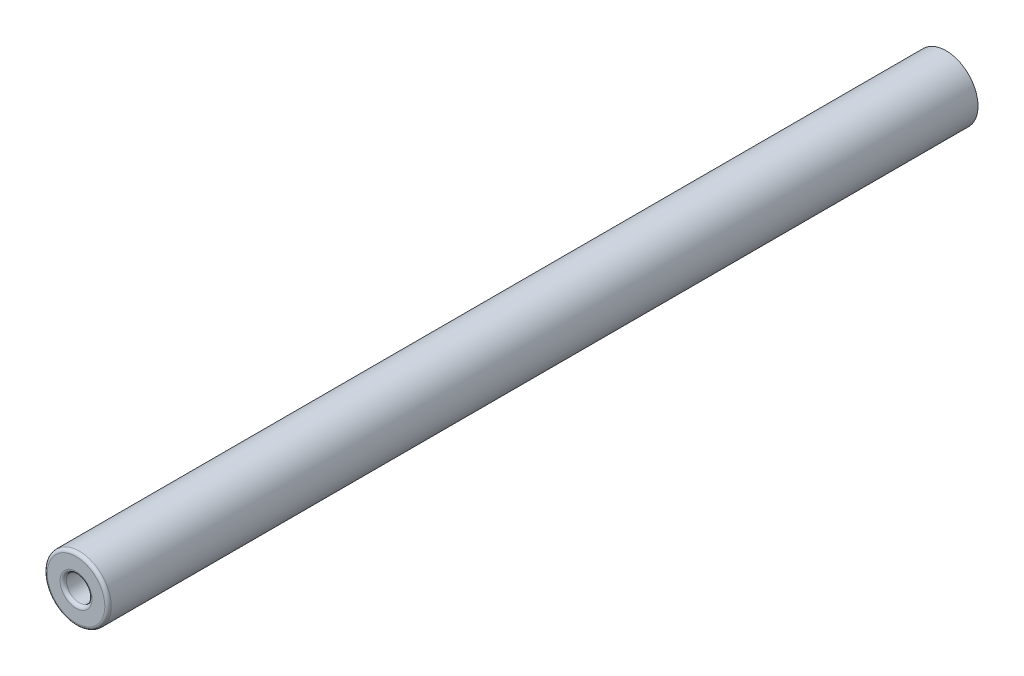
from build123d import *

# Parameters (mm, degrees)
SKETCH1_R           = 5
BOSS_EXTRUDE1_DEPTH = 136
SKETCH2_R           = 2
CUT_EXTRUDE1_DEPTH  = 20
FILLET1_R           = 0.5
FILLET2_R           = 0.5


with BuildPart() as part:
    # Sketch1 → Boss-Extrude1 (new body)
    with BuildSketch(Plane.XY):
        Circle(SKETCH1_R)
    extrude(amount=BOSS_EXTRUDE1_DEPTH)

    # Sketch2 → Cut-Extrude1 (cut)
    with BuildSketch(Plane.XY.offset(136)):
        Circle(SKETCH2_R)
    extrude(amount=-CUT_EXTRUDE1_DEPTH, mode=Mode.SUBTRACT)

    # Fillet1
    fillet1_edges = [part.edges().sort_by_distance(p)[0] for p in [
        (-5, 0, 136),
    ]]
    fillet(fillet1_edges, radius=FILLET1_R)

    # Fillet2
    fillet2_edges = [part.edges().sort_by_distance(p)[0] for p in [
        (-2, 0, 136),
    ]]
    fillet(fillet2_edges, radius=FILLET2_R)


solid = part.part
